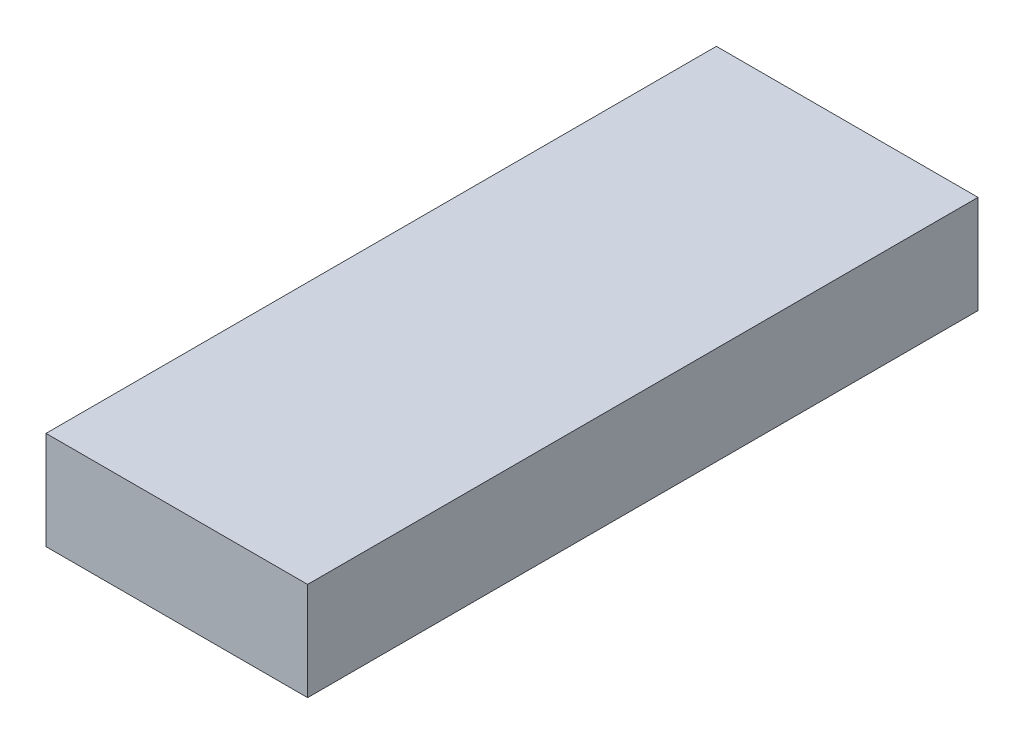
from build123d import *

# Parameters (mm, degrees)
SKETCH_1_W      = 80
SKETCH_1_H      = 205
EXTRUDE_1_DEPTH = 30


with BuildPart() as part:
    # Эскиз1 → Бобышка-Вытянуть1 (new body)
    with BuildSketch(Plane(origin=(0, 0, 0), x_dir=(1, 0, 0), z_dir=(0, 1, 0))):
        with Locations((40, 102.5)):
            Rectangle(SKETCH_1_W, SKETCH_1_H)
    extrude(amount=EXTRUDE_1_DEPTH)


solid = part.part
